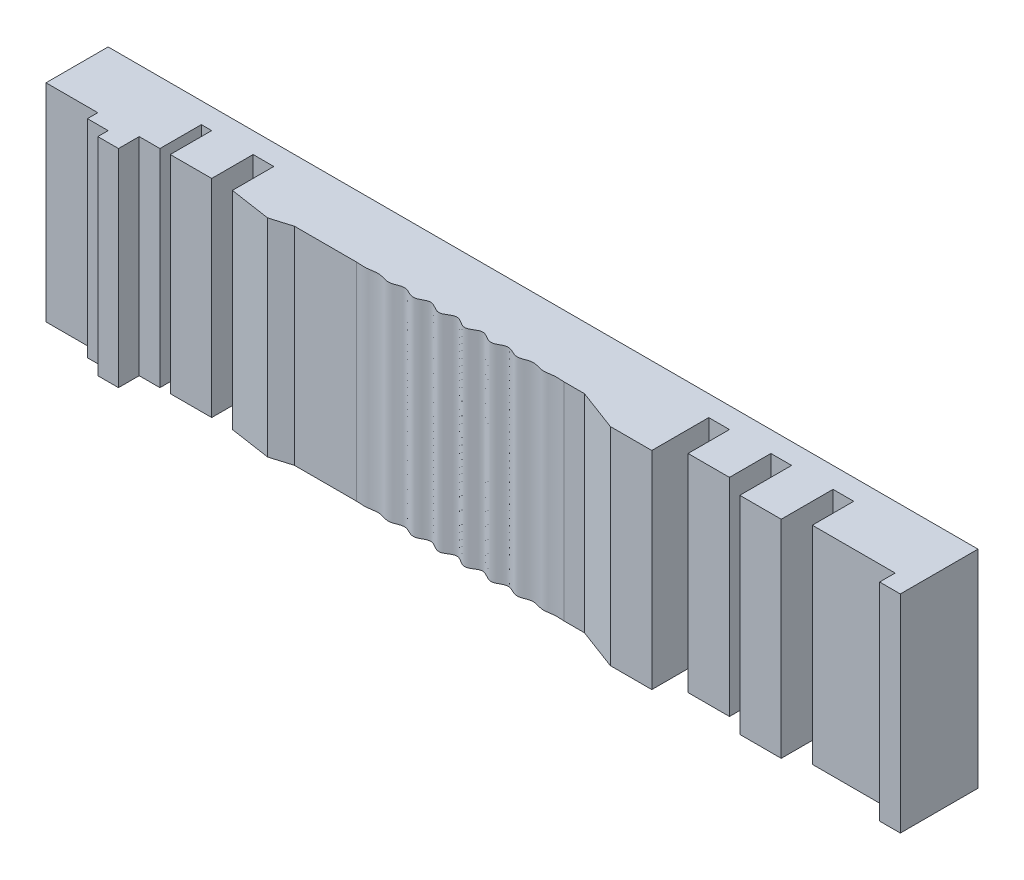
from build123d import *

# Parameters (mm, degrees)
EXTRUDE_1_DEPTH = 5


with BuildPart() as part:
    # 草图1 → 凸台-拉伸1 (new body, symmetric)
    with BuildSketch(Plane(origin=(0, 0, 0), x_dir=(1, 0, 0), z_dir=(0, 1, 0))):
        with BuildLine():
            Line((0, 0), (0, 3))
            Line((0, 3), (42, 3))
            Line((42, 3), (42, -0.75))
            Line((42, -0.75), (41, -0.75))
            Line((41, -0.75), (41, 0))
            Line((41, 0), (37, 0))
            Line((37, 0), (37, 2))
            Line((37, 2), (36, 2))
            Line((36, 2), (36, -0.5))
            Line((36, -0.5), (34, -0.5))
            Line((34, -0.5), (34, 2))
            Line((34, 2), (33, 2))
            Line((33, 2), (33, 0))
            Line((33, 0), (31, 0))
            Line((31, 0), (31, 2))
            Line((31, 2), (30, 2))
            Line((30, 2), (30, -0.75))
            Line((30, -0.75), (28, -0.75))
            Line((28, -0.75), (26, 0))
            Line((26, 0), (25, 0))
            add(Edge.make_bspline(
                [(15, 0), (15.019852379, 0), (15.060190558, -0.000731178), (15.170958225, -0.004993424), (15.304514791, -0.017003842), (15.474252144, -0.021487702), (15.68874463, 0.004937048), (15.893861657, 0.051909588), (16.094951986, 0.044850487), (16.295817919, -0.009198636), (16.472538126, -0.066588084), (16.69222545, -0.079729643), (16.888335149, 0.000528924), (17.057792019, 0.071283945), (17.21996953, 0.094390627), (17.347292458, 0.072033865), (17.465227624, 0.024389734), (17.578141197, -0.031891345), (17.698483931, -0.084840948), (17.835520741, -0.113450201), (17.97049161, -0.086701778), (18.088481622, -0.029788445), (18.195304005, 0.029919779), (18.296356752, 0.08125789), (18.419356141, 0.120991981), (18.565356334, 0.111821211), (18.707223229, 0.039142021), (18.849825719, -0.049006587), (19.004553287, -0.12913704), (19.182498155, -0.125477201), (19.333914462, -0.040957938), (19.473953485, 0.048104078), (19.625939165, 0.131731177), (19.803927697, 0.130852507), (19.955368453, 0.04586001), (20.095152965, -0.044159697), (20.246692264, -0.130036088), (20.425953601, -0.13233286), (20.579865028, -0.047628059), (20.721610821, 0.042597321), (20.875124879, 0.126850879), (21.052917266, 0.126831512), (21.205681567, 0.047140906), (21.346635582, -0.039353707), (21.485341862, -0.109599979), (21.626264904, -0.120139718), (21.74489324, -0.085169656), (21.841126768, -0.038617733), (21.945725191, 0.019145441), (22.061511684, 0.07771784), (22.228121545, 0.120686636), (22.399545356, 0.071438402), (22.54263056, -0.004711258), (22.687559945, -0.064819036), (22.80938576, -0.090770941), (22.933479525, -0.081171782), (23.050482764, -0.045843176), (23.160886922, -0.001969054), (23.270309992, 0.037903038), (23.407269761, 0.0699359), (23.598735058, 0.065525517), (23.820769111, -0.018043876), (24.077234518, -0.062657182), (24.323354641, -0.012520022), (24.534895962, 0.01664141), (24.70139475, 0.017113956), (24.832869481, 0.006461173), (24.940989195, 0.001444486), (24.980546523, 0.000255205), (25, 0)],
                knots=[0.080420158, 0.080420158, 0.080420158, 0.080420158, 0.080420158, 0.08798504, 0.095549922, 0.110679687, 0.125809451, 0.140939215, 0.16517557, 0.177293748, 0.189411925, 0.207122949, 0.224833973, 0.245520981, 0.255864485, 0.266207988, 0.276282774, 0.28635756, 0.296432346, 0.306507132, 0.318373913, 0.330240694, 0.339311626, 0.348382559, 0.357453492, 0.366524424, 0.380143825, 0.393763225, 0.407382626, 0.421002027, 0.434517018, 0.448032009, 0.461547, 0.475061991, 0.488607776, 0.502153562, 0.515699347, 0.529245132, 0.542954524, 0.556663916, 0.570373307, 0.584082699, 0.597491202, 0.610899704, 0.624308207, 0.637716709, 0.646276459, 0.65483621, 0.66339596, 0.67195571, 0.684299222, 0.696642734, 0.716675493, 0.726691872, 0.736708251, 0.746449596, 0.75619094, 0.765932285, 0.77567363, 0.784483857, 0.793294084, 0.810914537, 0.835554636, 0.860194735, 0.875021766, 0.889848798, 0.904675829, 0.912089345, 0.919502861, 0.919502861, 0.919502861, 0.919502861, 0.919502861], degree=4))
            Line((15, 0), (12, 0))
            Line((12, 0), (11, -0.3))
            Line((11, -0.3), (9, 0))
            Line((9, 0), (9, 2))
            Line((9, 2), (8, 2))
            Line((8, 2), (8, 0))
            Line((8, 0), (6, 0))
            Line((6, 0), (6, 2))
            Line((6, 2), (5.5, 2))
            Line((5.5, 2), (5.5, 0))
            Line((5.5, 0), (4.5, 0))
            Line((4.5, 0), (4.5, -1))
            Line((4.5, -1), (3.5, -1))
            Line((3.5, -1), (3.5, -0.5))
            Line((3.5, -0.5), (2.5, -0.5))
            Line((2.5, -0.5), (2.5, 0))
            Line((2.5, 0), (0, 0))
        make_face()
    extrude(amount=EXTRUDE_1_DEPTH, both=True)


solid = part.part
